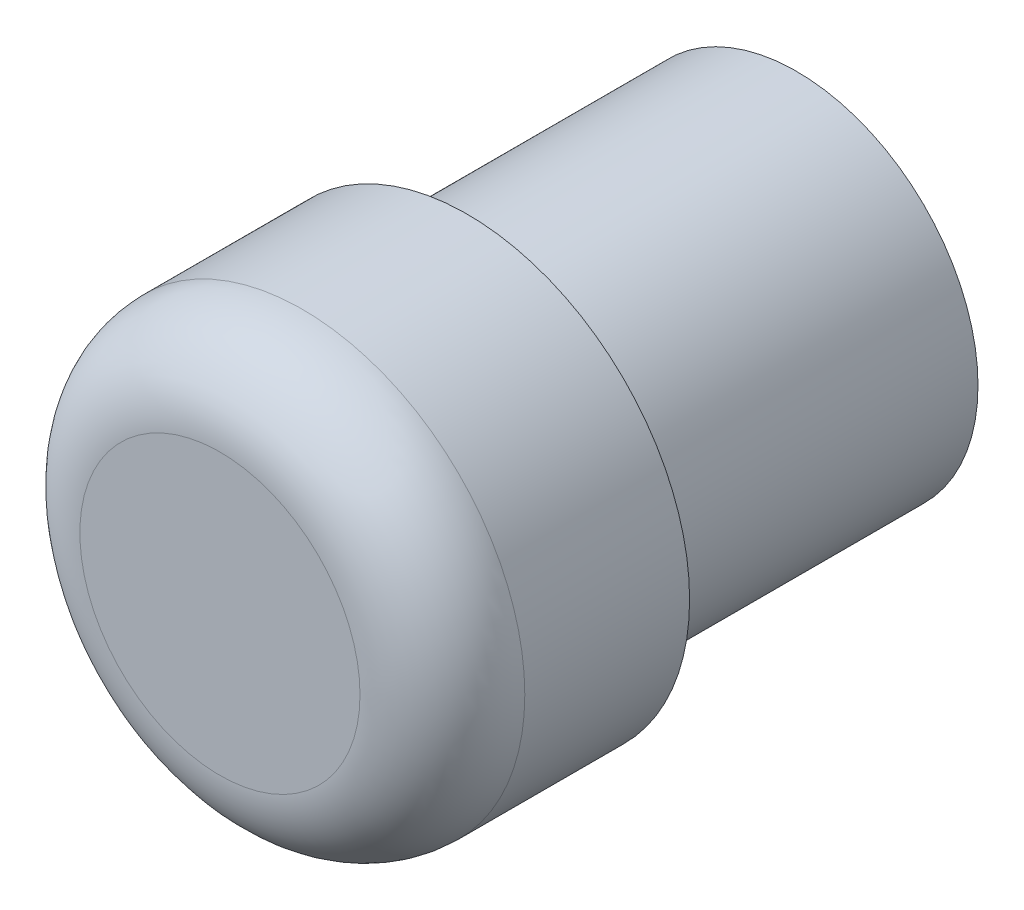
from build123d import *

# Parameters (mm, degrees)
SKETCH_1_R      = 11
EXTRUDE_1_DEPTH = 20
SKETCH_2_R      = 13.5
EXTRUDE_2_DEPTH = 15
FILLET_1_R      = 5


with BuildPart() as part:
    # 草图1 → 凸台-拉伸1 (new body)
    with BuildSketch(Plane.XY):
        with Locations((-173.275516994, 0)):
            Circle(SKETCH_1_R)
    extrude(amount=EXTRUDE_1_DEPTH)

    # 草图2 → 凸台-拉伸2 (add)
    with BuildSketch(Plane.XY.offset(20)):
        with Locations((-173.275516994, 0)):
            Circle(SKETCH_2_R)
    extrude(amount=EXTRUDE_2_DEPTH)

    # 圆角1
    fillet_1_edges = [part.edges().sort_by_distance(p)[0] for p in [
        (-186.775516994, 0, 35),
    ]]
    fillet(fillet_1_edges, radius=FILLET_1_R)


solid = part.part
